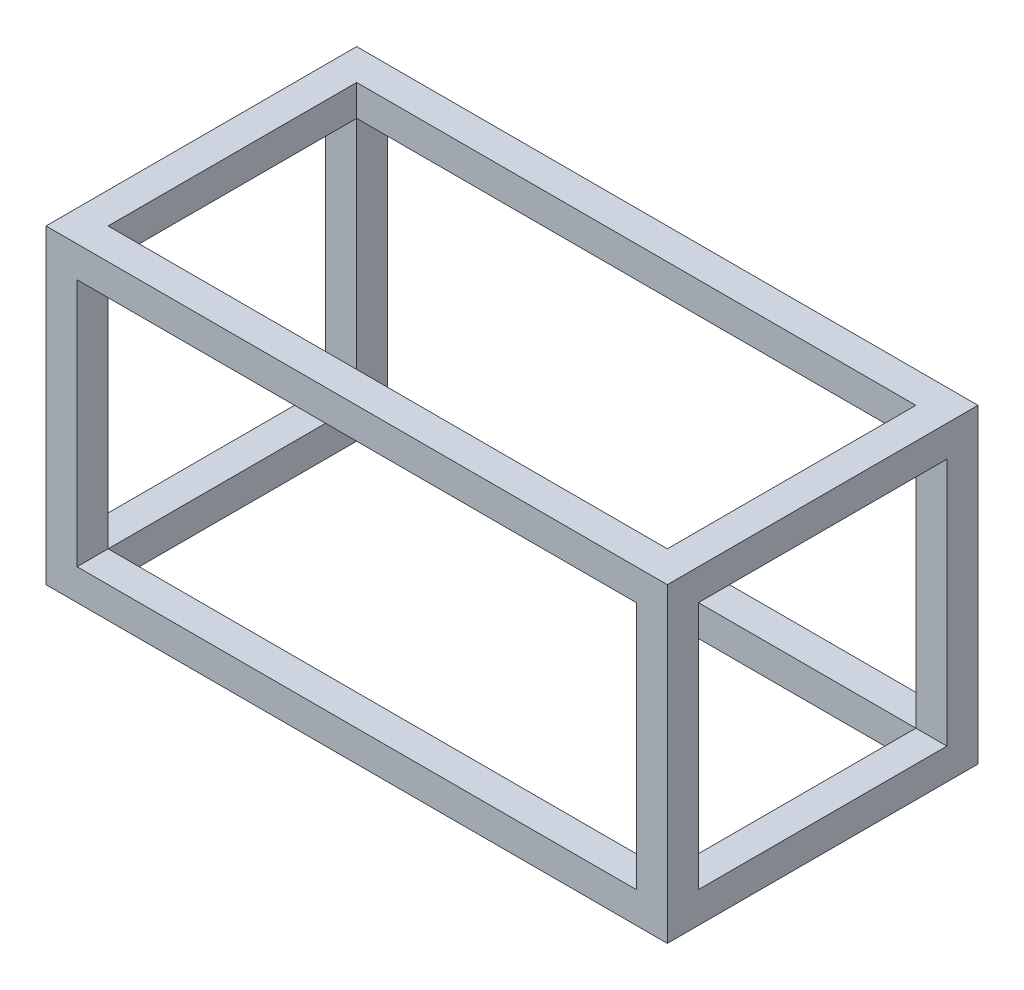
from build123d import *

# Parameters (mm, degrees)
SKETCH1_W           = 100
SKETCH1_H           = 50
SKETCH1_W_2         = 90
SKETCH1_H_2         = 40
BOSS_EXTRUDE1_DEPTH = 50
SKETCH2_W           = 40
SKETCH2_H           = 40
CUT_EXTRUDE1_DEPTH  = 101
SKETCH3_W           = 90
SKETCH3_H           = 40
CUT_EXTRUDE2_DEPTH  = 51


with BuildPart() as part:
    # Sketch1 → Boss-Extrude1 (new body)
    with BuildSketch(Plane(origin=(0, 0, 0), x_dir=(1, 0, 0), z_dir=(0, 1, 0))):
        with Locations((50, 25)):
            Rectangle(SKETCH1_W, SKETCH1_H)
        with Locations((50, 25)):
            Rectangle(SKETCH1_W_2, SKETCH1_H_2, mode=Mode.SUBTRACT)
    extrude(amount=BOSS_EXTRUDE1_DEPTH)

    # Sketch2 → Cut-Extrude1 (cut, through all)
    with BuildSketch(Plane(origin=(100, 0, 0), x_dir=(0, 0, -1), z_dir=(1, 0, 0))):
        with Locations((25, 25)):
            Rectangle(SKETCH2_W, SKETCH2_H)
    extrude(amount=-CUT_EXTRUDE1_DEPTH, mode=Mode.SUBTRACT)

    # Sketch3 → Cut-Extrude2 (cut, through all)
    with BuildSketch(Plane.XY):
        with Locations((50, 25)):
            Rectangle(SKETCH3_W, SKETCH3_H)
    extrude(amount=-CUT_EXTRUDE2_DEPTH, mode=Mode.SUBTRACT)


solid = part.part
